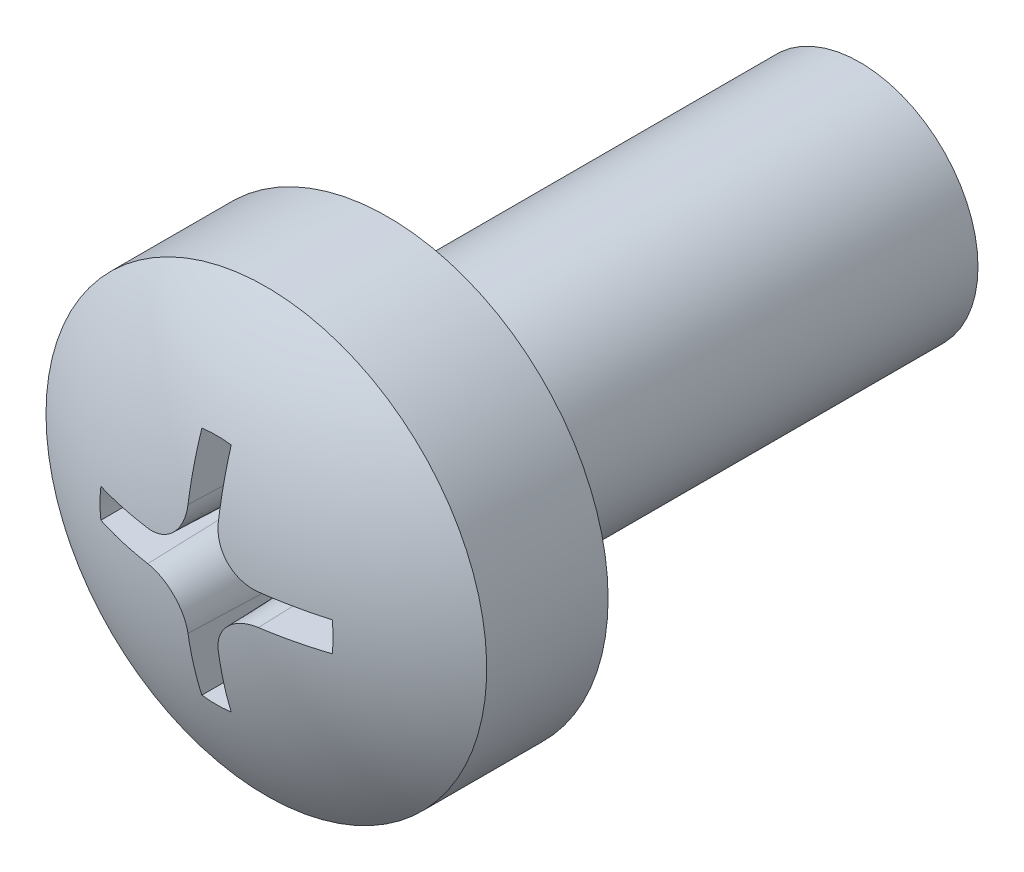
from build123d import *

# Parameters (mm, degrees)
SKETCH1_R          = 1.5
BASE_EXTRUDE_DEPTH = 6
CUT_EXTRUDE1_DEPTH = 1.799999969
CUT_EXTRUDE1_TAPER = 2


with BuildPart() as part:
    # Sketch1 → Base-Extrude (new body)
    with BuildSketch(Plane.XY):
        Circle(SKETCH1_R)
    extrude(amount=BASE_EXTRUDE_DEPTH)

    # Sketch6 → Boss-Revolve2 (revolve)
    with BuildSketch(Plane(origin=(0, 0, 0), x_dir=(1, 0, 0), z_dir=(0, 1, 0))):
        with BuildLine():
            Line((0, -6), (2.7999999, -6))
            Line((2.7999999, -6), (2.7999999, -7.54246308))
            ThreePointArc((2.7999999, -7.54246308), (1.46418655, -8.180811406), (0, -8.4))
            Line((0, -8.4), (0, -6))
        make_face()
    revolve(axis=Axis((0, 0, -0.393620135), (0, 0, 1)))

    # Sketch7 → Cut-Extrude1 (cut)
    with BuildSketch(Plane(origin=(0, 0, 8.7000001), x_dir=(-1, 0, 0), z_dir=(0, 0, -1))):
        with BuildLine():
            ThreePointArc((0.205000004, 1.48592565), (0, 1.500000013), (-0.205000004, 1.48592565))
            Line((-0.205000004, 1.48592565), (-0.205000004, 0.708178558))
            ThreePointArc((-0.205000004, 0.708178558), (-0.35072876, 0.355344481), (-0.702967546, 0.208182689))
            Line((-0.702967546, 0.208182689), (-1.48592565, 0.205000004))
            ThreePointArc((-1.48592565, 0.205000004), (-1.500000013, 0), (-1.48592565, -0.205000004))
            Line((-1.48592565, -0.205000004), (-0.702967546, -0.208182689))
            ThreePointArc((-0.702967546, -0.208182689), (-0.35072876, -0.355344481), (-0.205000004, -0.708178558))
            Line((-0.205000004, -0.708178558), (-0.205000004, -1.48592565))
            ThreePointArc((-0.205000004, -1.48592565), (0, -1.500000013), (0.205000004, -1.48592565))
            Line((0.205000004, -1.48592565), (0.205000004, -0.708178558))
            ThreePointArc((0.205000004, -0.708178558), (0.35072876, -0.355344481), (0.702967546, -0.208182689))
            Line((0.702967546, -0.208182689), (1.48592565, -0.205000004))
            ThreePointArc((1.48592565, -0.205000004), (1.500000013, 0), (1.48592565, 0.205000004))
            Line((1.48592565, 0.205000004), (0.702967546, 0.208182689))
            ThreePointArc((0.702967546, 0.208182689), (0.35072876, 0.355344481), (0.205000004, 0.708178558))
            Line((0.205000004, 0.708178558), (0.205000004, 1.48592565))
        make_face()
    extrude(amount=CUT_EXTRUDE1_DEPTH, taper=CUT_EXTRUDE1_TAPER, mode=Mode.SUBTRACT)


solid = part.part
